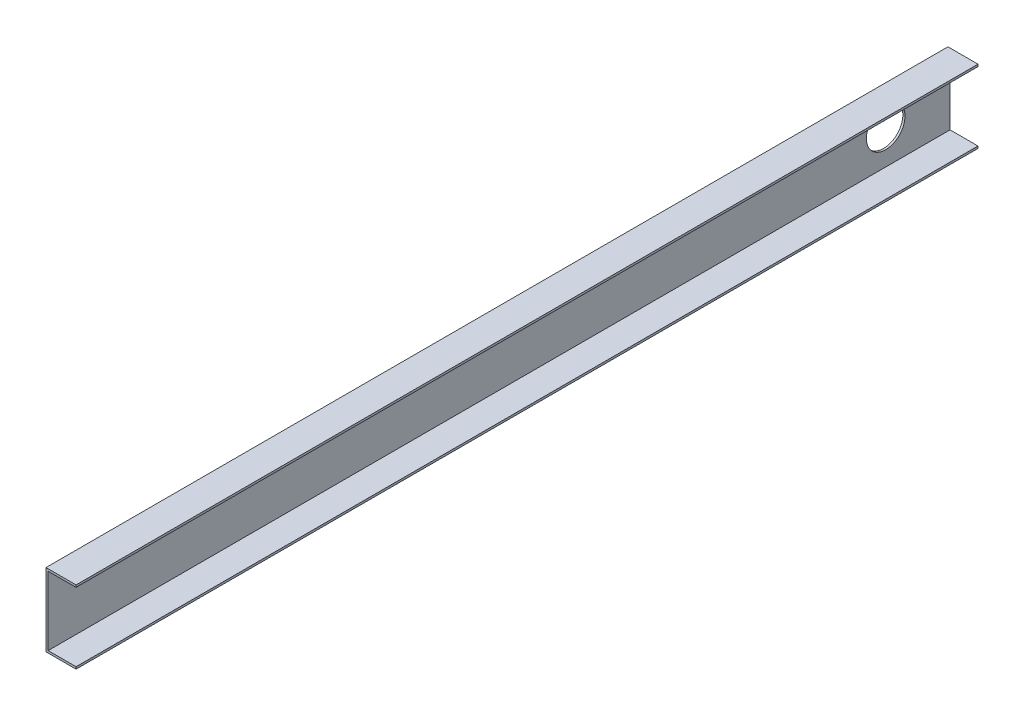
from build123d import *

# Parameters (mm, degrees)
RESSALTO_EXTRUS_O1_DEPTH = 210
ESBO_O3_R                = 4.5
CORTE_EXTRUS_O1_DEPTH    = 10


with BuildPart() as part:
    # Esboço1 → Ressalto-extrusão1 (new body)
    with BuildSketch(Plane.XY):
        Polygon((0, -8.5), (0, 8.5), (7, 8.5), (7, 8), (0.5, 8), (0.5, -8), (7, -8), (7, -8.5), align=None)
    extrude(amount=RESSALTO_EXTRUS_O1_DEPTH)

    # Esboço3 → Corte-extrusão1 (cut)
    with BuildSketch(Plane.ZY):
        with Locations((15, 0)):
            Circle(ESBO_O3_R)
    extrude(amount=-CORTE_EXTRUS_O1_DEPTH, mode=Mode.SUBTRACT)


solid = part.part
